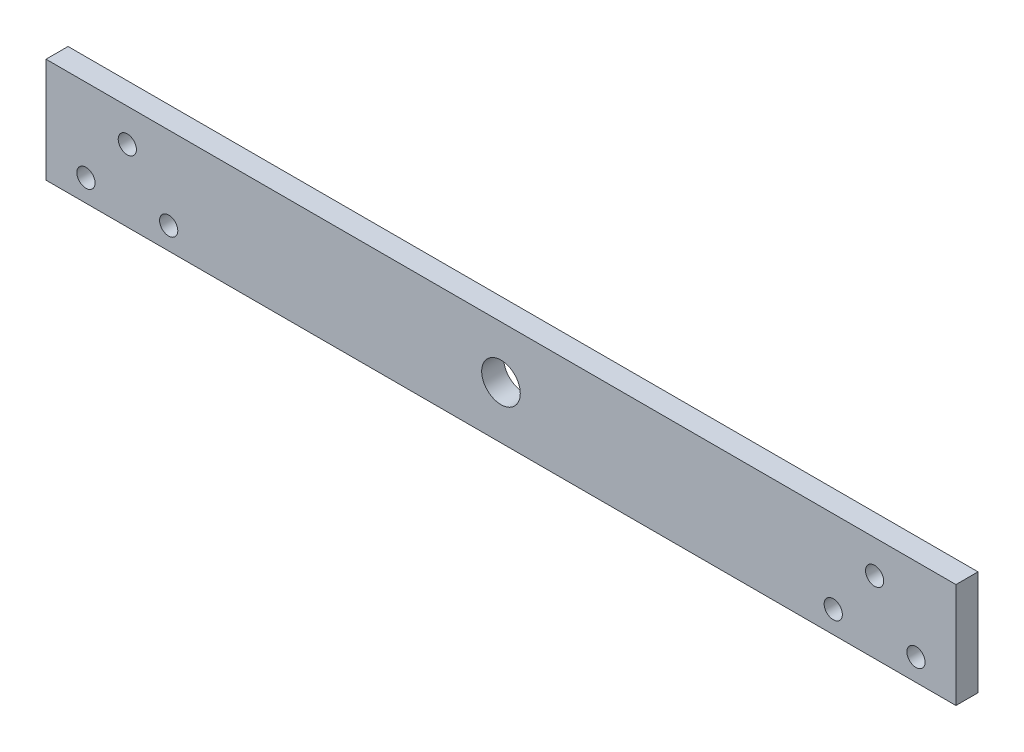
from build123d import *

# Parameters (mm, degrees)
SKETCH2_W           = 330
SKETCH2_H           = 38
BOSS_EXTRUDE1_DEPTH = 8
SKETCH3_R           = 7
CUT_EXTRUDE1_DEPTH  = 9
SKETCH4_R           = 3.3
CUT_EXTRUDE2_DEPTH  = 9


with BuildPart() as part:
    # Sketch2 → Boss-Extrude1 (new body)
    with BuildSketch(Plane.XY):
        Rectangle(SKETCH2_W, SKETCH2_H)
    extrude(amount=BOSS_EXTRUDE1_DEPTH)

    # Sketch3 → Cut-Extrude1 (cut, through all)
    with BuildSketch(Plane.XY.offset(8)):
        Circle(SKETCH3_R)
    extrude(amount=-CUT_EXTRUDE1_DEPTH, mode=Mode.SUBTRACT)

    # Sketch4 → Cut-Extrude2 (cut, through all)
    with BuildSketch(Plane.XY.offset(8)):
        with Locations((-135.508311731, 7)):
            Circle(SKETCH4_R)
        with Locations((-120.508311731, -11)):
            Circle(SKETCH4_R)
        with Locations((-150.508311731, -11)):
            Circle(SKETCH4_R)
    cut_extrude2 = extrude(amount=-CUT_EXTRUDE2_DEPTH, mode=Mode.SUBTRACT)

    # Mirror1: Cut-Extrude2 across plane
    add(cut_extrude2.mirror(Plane(origin=(0, 0, 0), x_dir=(0, 0, 1), z_dir=(1, 0, 0))), mode=Mode.SUBTRACT)


solid = part.part
